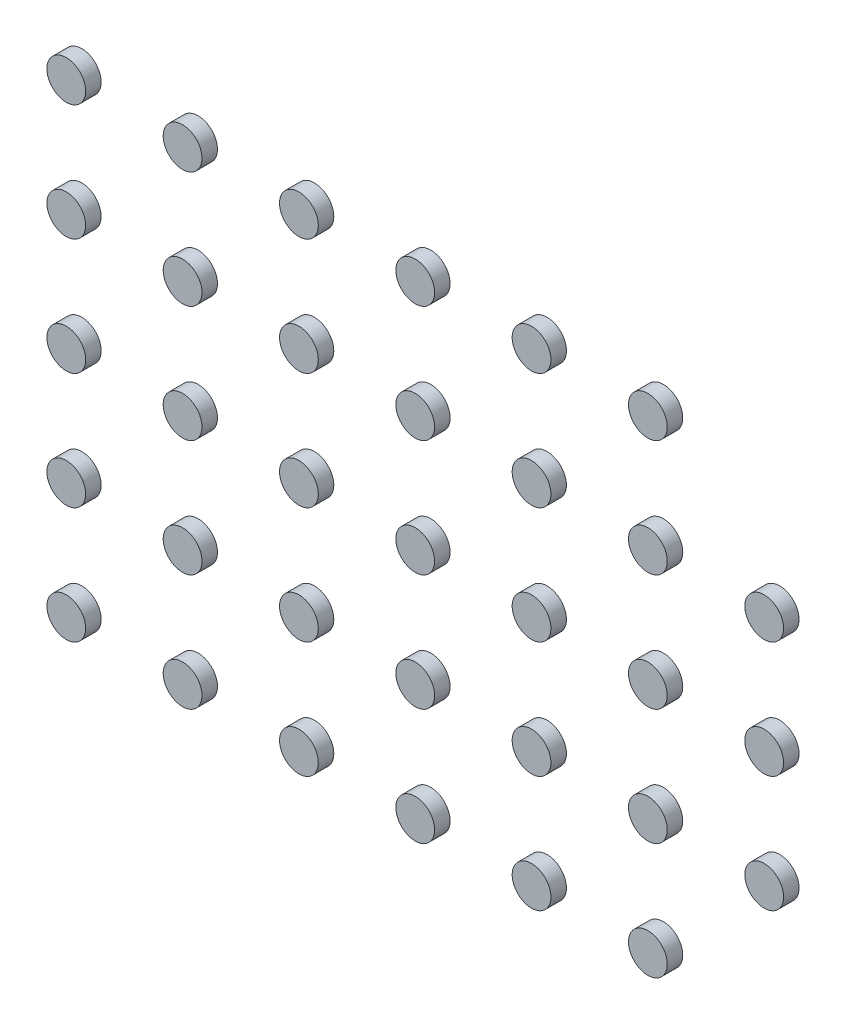
from build123d import *

# Parameters (mm, degrees)
SKETCH_1_R         = 0.5
EXTRUDE_1_DEPTH    = 0.4
EXTRUDE_1_2_DEPTH  = 0.4
EXTRUDE_1_3_DEPTH  = 0.4
EXTRUDE_1_4_DEPTH  = 0.4
EXTRUDE_1_5_DEPTH  = 0.4
EXTRUDE_1_6_DEPTH  = 0.4
EXTRUDE_1_7_DEPTH  = 0.4
EXTRUDE_1_8_DEPTH  = 0.4
EXTRUDE_1_9_DEPTH  = 0.4
EXTRUDE_1_10_DEPTH = 0.4
EXTRUDE_1_11_DEPTH = 0.4
EXTRUDE_1_12_DEPTH = 0.4
EXTRUDE_1_13_DEPTH = 0.4
EXTRUDE_1_14_DEPTH = 0.4
EXTRUDE_1_15_DEPTH = 0.4
EXTRUDE_1_16_DEPTH = 0.4
EXTRUDE_1_17_DEPTH = 0.4
EXTRUDE_1_18_DEPTH = 0.4
EXTRUDE_1_19_DEPTH = 0.4
EXTRUDE_1_20_DEPTH = 0.4
EXTRUDE_1_21_DEPTH = 0.4
EXTRUDE_1_22_DEPTH = 0.4
EXTRUDE_1_23_DEPTH = 0.4
EXTRUDE_1_24_DEPTH = 0.4
EXTRUDE_1_25_DEPTH = 0.4
EXTRUDE_1_26_DEPTH = 0.4
EXTRUDE_1_27_DEPTH = 0.4
EXTRUDE_1_28_DEPTH = 0.4
EXTRUDE_1_29_DEPTH = 0.4
EXTRUDE_1_30_DEPTH = 0.4
EXTRUDE_1_31_DEPTH = 0.4
EXTRUDE_1_32_DEPTH = 0.4
EXTRUDE_1_33_DEPTH = 0.4
EXTRUDE_1_34_DEPTH = 0.4
EXTRUDE_1_35_DEPTH = 0.4
EXTRUDE_1_36_DEPTH = 0.4
EXTRUDE_1_37_DEPTH = 0.4
EXTRUDE_1_38_DEPTH = 0.4
EXTRUDE_1_39_DEPTH = 0.4
EXTRUDE_1_40_DEPTH = 0.4
EXTRUDE_1_41_DEPTH = 0.4
EXTRUDE_1_42_DEPTH = 0.4


with BuildPart() as part:
    # 草图1 → 凸台-拉伸1 (new body)
    with BuildSketch(Plane.XY):
        with Locations((-4.5, 1.5)):
            Circle(SKETCH_1_R)
    extrude(amount=EXTRUDE_1_DEPTH)


with BuildPart() as body_2:
    # 草图1 → Extrude 1 2 (new body)
    with BuildSketch(Plane.XY):
        with Locations((-1.5, 1.5)):
            Circle(SKETCH_1_R)
    extrude(amount=EXTRUDE_1_2_DEPTH)


with BuildPart() as body_3:
    # 草图1 → Extrude 1 3 (new body)
    with BuildSketch(Plane.XY):
        with Locations((1.5, 1.5)):
            Circle(SKETCH_1_R)
    extrude(amount=EXTRUDE_1_3_DEPTH)


with BuildPart() as body_4:
    # 草图1 → Extrude 1 4 (new body)
    with BuildSketch(Plane.XY):
        with Locations((4.5, 1.5)):
            Circle(SKETCH_1_R)
    extrude(amount=EXTRUDE_1_4_DEPTH)


with BuildPart() as body_5:
    # 草图1 → Extrude 1 5 (new body)
    with BuildSketch(Plane.XY):
        with Locations((7.5, 1.5)):
            Circle(SKETCH_1_R)
    extrude(amount=EXTRUDE_1_5_DEPTH)


with BuildPart() as body_6:
    # 草图1 → Extrude 1 6 (new body)
    with BuildSketch(Plane.XY):
        with Locations((10.5, 1.5)):
            Circle(SKETCH_1_R)
    extrude(amount=EXTRUDE_1_6_DEPTH)


with BuildPart() as body_7:
    # 草图1 → Extrude 1 7 (new body)
    with BuildSketch(Plane.XY):
        with Locations((10.5, -1.5)):
            Circle(SKETCH_1_R)
    extrude(amount=EXTRUDE_1_7_DEPTH)


with BuildPart() as body_8:
    # 草图1 → Extrude 1 8 (new body)
    with BuildSketch(Plane.XY):
        with Locations((7.5, -1.5)):
            Circle(SKETCH_1_R)
    extrude(amount=EXTRUDE_1_8_DEPTH)


with BuildPart() as body_9:
    # 草图1 → Extrude 1 9 (new body)
    with BuildSketch(Plane.XY):
        with Locations((-10.5, 7.5)):
            Circle(SKETCH_1_R)
    extrude(amount=EXTRUDE_1_9_DEPTH)


with BuildPart() as body_10:
    # 草图1 → Extrude 1 10 (new body)
    with BuildSketch(Plane.XY):
        with Locations((-1.5, 7.5)):
            Circle(SKETCH_1_R)
    extrude(amount=EXTRUDE_1_10_DEPTH)


with BuildPart() as body_11:
    # 草图1 → Extrude 1 11 (new body)
    with BuildSketch(Plane.XY):
        with Locations((1.5, 7.5)):
            Circle(SKETCH_1_R)
    extrude(amount=EXTRUDE_1_11_DEPTH)


with BuildPart() as body_12:
    # 草图1 → Extrude 1 12 (new body)
    with BuildSketch(Plane.XY):
        with Locations((4.5, 7.5)):
            Circle(SKETCH_1_R)
    extrude(amount=EXTRUDE_1_12_DEPTH)


with BuildPart() as body_13:
    # 草图1 → Extrude 1 13 (new body)
    with BuildSketch(Plane.XY):
        with Locations((-10.5, 1.5)):
            Circle(SKETCH_1_R)
    extrude(amount=EXTRUDE_1_13_DEPTH)


with BuildPart() as body_14:
    # 草图1 → Extrude 1 14 (new body)
    with BuildSketch(Plane.XY):
        with Locations((-10.5, 4.5)):
            Circle(SKETCH_1_R)
    extrude(amount=EXTRUDE_1_14_DEPTH)


with BuildPart() as body_15:
    # 草图1 → Extrude 1 15 (new body)
    with BuildSketch(Plane.XY):
        with Locations((-10.5, -1.5)):
            Circle(SKETCH_1_R)
    extrude(amount=EXTRUDE_1_15_DEPTH)


with BuildPart() as body_16:
    # 草图1 → Extrude 1 16 (new body)
    with BuildSketch(Plane.XY):
        with Locations((-10.5, -4.5)):
            Circle(SKETCH_1_R)
    extrude(amount=EXTRUDE_1_16_DEPTH)


with BuildPart() as body_17:
    # 草图1 → Extrude 1 17 (new body)
    with BuildSketch(Plane.XY):
        with Locations((-10.5, -7.5)):
            Circle(SKETCH_1_R)
    extrude(amount=EXTRUDE_1_17_DEPTH)


with BuildPart() as body_18:
    # 草图1 → Extrude 1 18 (new body)
    with BuildSketch(Plane.XY):
        with Locations((-7.5, -7.5)):
            Circle(SKETCH_1_R)
    extrude(amount=EXTRUDE_1_18_DEPTH)


with BuildPart() as body_19:
    # 草图1 → Extrude 1 19 (new body)
    with BuildSketch(Plane.XY):
        with Locations((-7.5, -4.5)):
            Circle(SKETCH_1_R)
    extrude(amount=EXTRUDE_1_19_DEPTH)


with BuildPart() as body_20:
    # 草图1 → Extrude 1 20 (new body)
    with BuildSketch(Plane.XY):
        with Locations((-7.5, -1.5)):
            Circle(SKETCH_1_R)
    extrude(amount=EXTRUDE_1_20_DEPTH)


with BuildPart() as body_21:
    # 草图1 → Extrude 1 21 (new body)
    with BuildSketch(Plane.XY):
        with Locations((-7.5, 1.5)):
            Circle(SKETCH_1_R)
    extrude(amount=EXTRUDE_1_21_DEPTH)


with BuildPart() as body_22:
    # 草图1 → Extrude 1 22 (new body)
    with BuildSketch(Plane.XY):
        with Locations((-7.5, 4.5)):
            Circle(SKETCH_1_R)
    extrude(amount=EXTRUDE_1_22_DEPTH)


with BuildPart() as body_23:
    # 草图1 → Extrude 1 23 (new body)
    with BuildSketch(Plane.XY):
        with Locations((-4.5, 4.5)):
            Circle(SKETCH_1_R)
    extrude(amount=EXTRUDE_1_23_DEPTH)


with BuildPart() as body_24:
    # 草图1 → Extrude 1 24 (new body)
    with BuildSketch(Plane.XY):
        with Locations((-1.5, 4.5)):
            Circle(SKETCH_1_R)
    extrude(amount=EXTRUDE_1_24_DEPTH)


with BuildPart() as body_25:
    # 草图1 → Extrude 1 25 (new body)
    with BuildSketch(Plane.XY):
        with Locations((1.5, 4.5)):
            Circle(SKETCH_1_R)
    extrude(amount=EXTRUDE_1_25_DEPTH)


with BuildPart() as body_26:
    # 草图1 → Extrude 1 26 (new body)
    with BuildSketch(Plane.XY):
        with Locations((7.5, 4.5)):
            Circle(SKETCH_1_R)
    extrude(amount=EXTRUDE_1_26_DEPTH)


with BuildPart() as body_27:
    # 草图1 → Extrude 1 27 (new body)
    with BuildSketch(Plane.XY):
        with Locations((1.5, -1.5)):
            Circle(SKETCH_1_R)
    extrude(amount=EXTRUDE_1_27_DEPTH)


with BuildPart() as body_28:
    # 草图1 → Extrude 1 28 (new body)
    with BuildSketch(Plane.XY):
        with Locations((-1.5, -1.5)):
            Circle(SKETCH_1_R)
    extrude(amount=EXTRUDE_1_28_DEPTH)


with BuildPart() as body_29:
    # 草图1 → Extrude 1 29 (new body)
    with BuildSketch(Plane.XY):
        with Locations((-4.5, -1.5)):
            Circle(SKETCH_1_R)
    extrude(amount=EXTRUDE_1_29_DEPTH)


with BuildPart() as body_30:
    # 草图1 → Extrude 1 30 (new body)
    with BuildSketch(Plane.XY):
        with Locations((-4.5, -4.5)):
            Circle(SKETCH_1_R)
    extrude(amount=EXTRUDE_1_30_DEPTH)


with BuildPart() as body_31:
    # 草图1 → Extrude 1 31 (new body)
    with BuildSketch(Plane.XY):
        with Locations((-1.5, -4.5)):
            Circle(SKETCH_1_R)
    extrude(amount=EXTRUDE_1_31_DEPTH)


with BuildPart() as body_32:
    # 草图1 → Extrude 1 32 (new body)
    with BuildSketch(Plane.XY):
        with Locations((-4.5, -7.5)):
            Circle(SKETCH_1_R)
    extrude(amount=EXTRUDE_1_32_DEPTH)


with BuildPart() as body_33:
    # 草图1 → Extrude 1 33 (new body)
    with BuildSketch(Plane.XY):
        with Locations((-1.5, -7.5)):
            Circle(SKETCH_1_R)
    extrude(amount=EXTRUDE_1_33_DEPTH)


with BuildPart() as body_34:
    # 草图1 → Extrude 1 34 (new body)
    with BuildSketch(Plane.XY):
        with Locations((1.5, -7.5)):
            Circle(SKETCH_1_R)
    extrude(amount=EXTRUDE_1_34_DEPTH)


with BuildPart() as body_35:
    # 草图1 → Extrude 1 35 (new body)
    with BuildSketch(Plane.XY):
        with Locations((4.5, -7.5)):
            Circle(SKETCH_1_R)
    extrude(amount=EXTRUDE_1_35_DEPTH)


with BuildPart() as body_36:
    # 草图1 → Extrude 1 36 (new body)
    with BuildSketch(Plane.XY):
        with Locations((4.5, -4.5)):
            Circle(SKETCH_1_R)
    extrude(amount=EXTRUDE_1_36_DEPTH)


with BuildPart() as body_37:
    # 草图1 → Extrude 1 37 (new body)
    with BuildSketch(Plane.XY):
        with Locations((7.5, -4.5)):
            Circle(SKETCH_1_R)
    extrude(amount=EXTRUDE_1_37_DEPTH)


with BuildPart() as body_38:
    # 草图1 → Extrude 1 38 (new body)
    with BuildSketch(Plane.XY):
        with Locations((4.5, -1.5)):
            Circle(SKETCH_1_R)
    extrude(amount=EXTRUDE_1_38_DEPTH)


with BuildPart() as body_39:
    # 草图1 → Extrude 1 39 (new body)
    with BuildSketch(Plane.XY):
        with Locations((-7.5, 7.5)):
            Circle(SKETCH_1_R)
    extrude(amount=EXTRUDE_1_39_DEPTH)


with BuildPart() as body_40:
    # 草图1 → Extrude 1 40 (new body)
    with BuildSketch(Plane.XY):
        with Locations((-4.5, 7.5)):
            Circle(SKETCH_1_R)
    extrude(amount=EXTRUDE_1_40_DEPTH)


with BuildPart() as body_41:
    # 草图1 → Extrude 1 41 (new body)
    with BuildSketch(Plane.XY):
        with Locations((4.5, 4.5)):
            Circle(SKETCH_1_R)
    extrude(amount=EXTRUDE_1_41_DEPTH)


with BuildPart() as body_42:
    # 草图1 → Extrude 1 42 (new body)
    with BuildSketch(Plane.XY):
        with Locations((1.5, -4.5)):
            Circle(SKETCH_1_R)
    extrude(amount=EXTRUDE_1_42_DEPTH)


solid = Compound([part.part, body_2.part, body_3.part, body_4.part, body_5.part, body_8.part, body_13.part, body_14.part, body_15.part, body_16.part, body_17.part, body_18.part, body_19.part, body_20.part, body_21.part, body_22.part, body_23.part, body_24.part, body_25.part, body_27.part, body_28.part, body_29.part, body_30.part, body_31.part, body_32.part, body_33.part, body_34.part, body_35.part, body_36.part, body_37.part, body_38.part, body_41.part, body_42.part])
